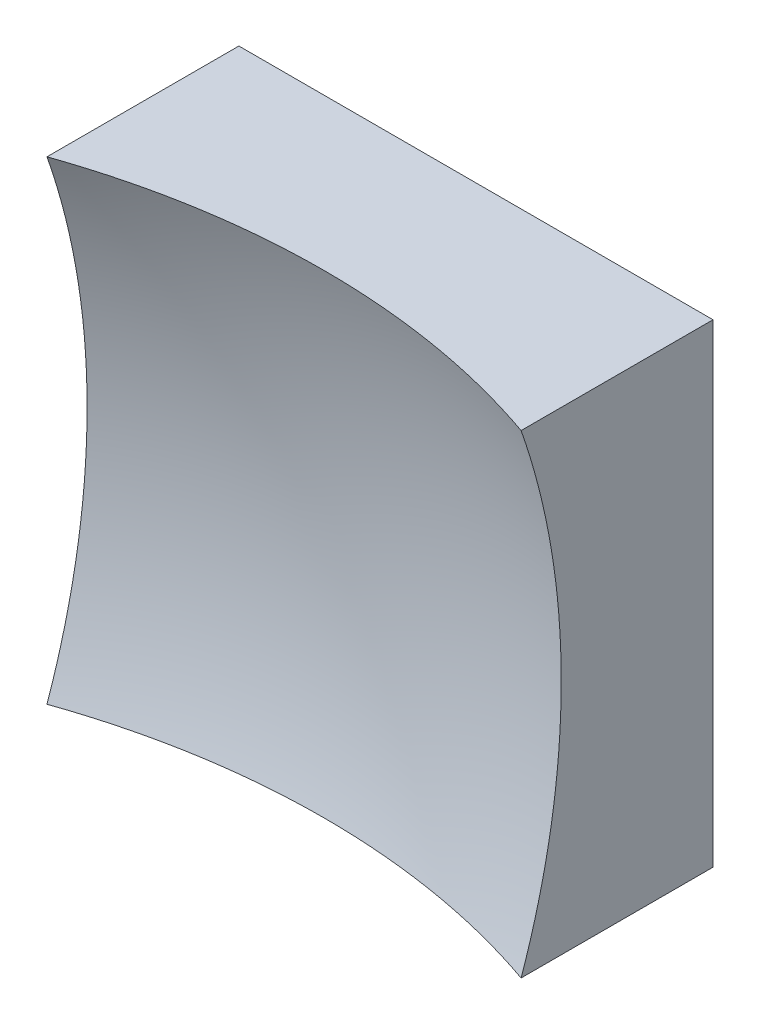
from build123d import *

# Parameters (mm, degrees)
SKETCH_1_W      = 25
SKETCH_1_H      = 25
EXTRUDE_1_DEPTH = 20


with BuildPart() as part:
    # 草图1 → 凸台-拉伸1 (new body)
    with BuildSketch(Plane.XY):
        Rectangle(SKETCH_1_W, SKETCH_1_H)
    extrude(amount=EXTRUDE_1_DEPTH)

    # 草图2 → 切除-旋转2 (revolve, cut)
    with BuildSketch(Plane(origin=(0, 0, 0), x_dir=(1, 0, 0), z_dir=(0, 1, 0))):
        with BuildLine():
            Line((38.993818473, -37.084725415), (0, -37.084725415))
            Line((0, -37.084725415), (0, -6))
            ThreePointArc((0, -6), (24.933802524, -14.722124565), (38.993818473, -37.084725415))
        make_face()
    revolve(axis=Axis((0, 0, 37.084725415), (0, 0, -1)), mode=Mode.SUBTRACT)


solid = part.part
